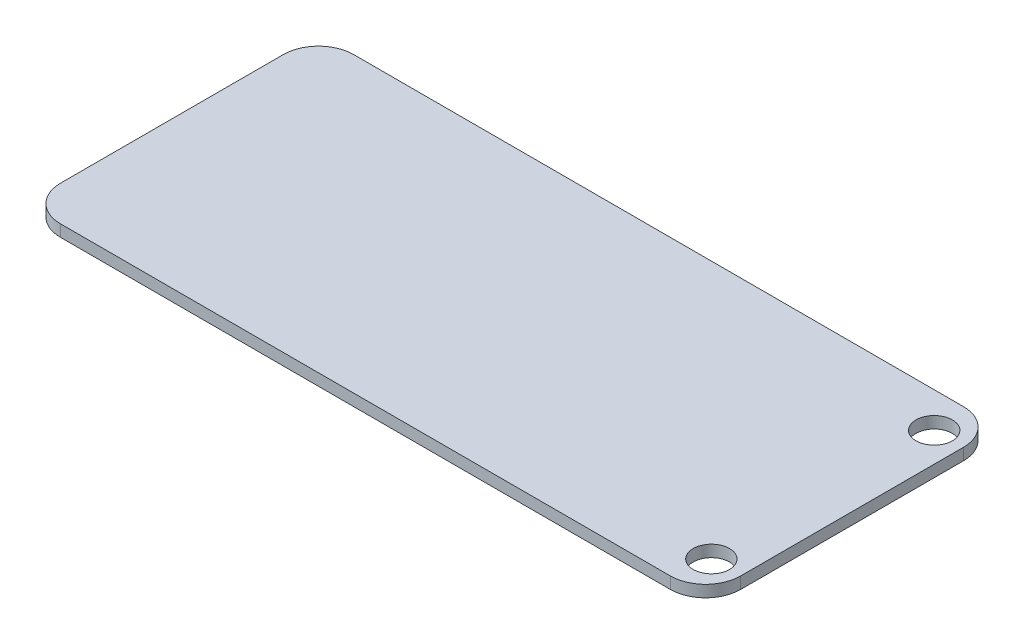
from build123d import *

# Parameters (mm, degrees)
SKETCH_1_W          = 58
SKETCH_1_H          = 25
EXTRUDE_1_DEPTH     = 1
SKETCH_2_R          = 1.55
CUT_EXTRUDE_1_DEPTH = 2
FILLET_1_R          = 3


with BuildPart() as part:
    # 草图1 → 凸台-拉伸1 (new body)
    with BuildSketch(Plane(origin=(0, 0, 0), x_dir=(1, 0, 0), z_dir=(0, 1, 0))):
        Rectangle(SKETCH_1_W, SKETCH_1_H)
    extrude(amount=EXTRUDE_1_DEPTH)

    # 草图2 → 切除-拉伸1 (cut, through all)
    with BuildSketch(Plane(origin=(0, 1, 0), x_dir=(1, 0, 0), z_dir=(0, 1, 0))):
        with Locations((26.5, 9.5)):
            Circle(SKETCH_2_R)
        with Locations((26.5, -9.5)):
            Circle(SKETCH_2_R)
    extrude(amount=-CUT_EXTRUDE_1_DEPTH, mode=Mode.SUBTRACT)

    # 圆角1
    fillet_1_edges = [part.edges().sort_by_distance(p)[0] for p in [
        (29, 0.5, 12.5),
        (-29, 0.5, 12.5),
        (-29, 0.5, -12.5),
        (29, 0.5, -12.5),
    ]]
    fillet(fillet_1_edges, radius=FILLET_1_R)


solid = part.part
